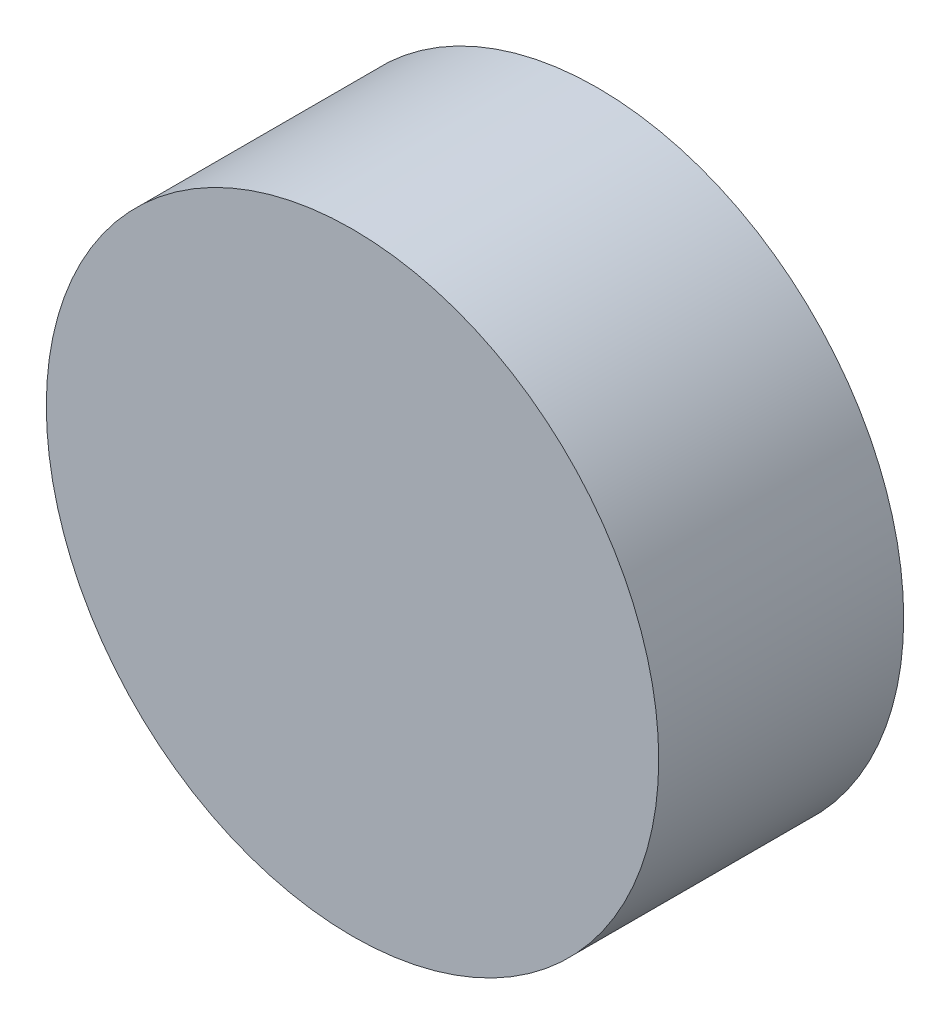
from build123d import *

# Parameters (mm, degrees)
SKETCH_1_R      = 2.5
EXTRUDE_1_DEPTH = 2


with BuildPart() as part:
    # 草图1 → 凸台-拉伸1 (new body)
    with BuildSketch(Plane.XY):
        Circle(SKETCH_1_R)
    extrude(amount=EXTRUDE_1_DEPTH)


solid = part.part
